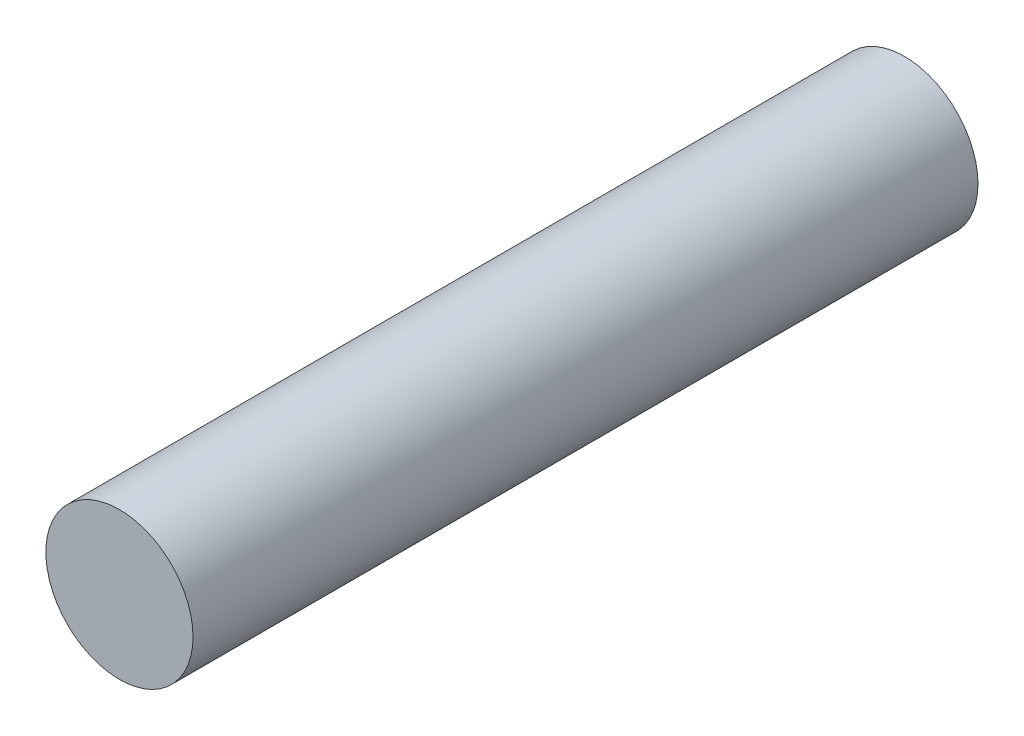
from build123d import *

# Parameters (mm, degrees)
SKETCH1_R           = 19.05
BOSS_EXTRUDE1_DEPTH = 203.2


with BuildPart() as part:
    # Sketch1 → Boss-Extrude1 (new body)
    with BuildSketch(Plane.XY):
        Circle(SKETCH1_R)
    extrude(amount=BOSS_EXTRUDE1_DEPTH)


solid = part.part
